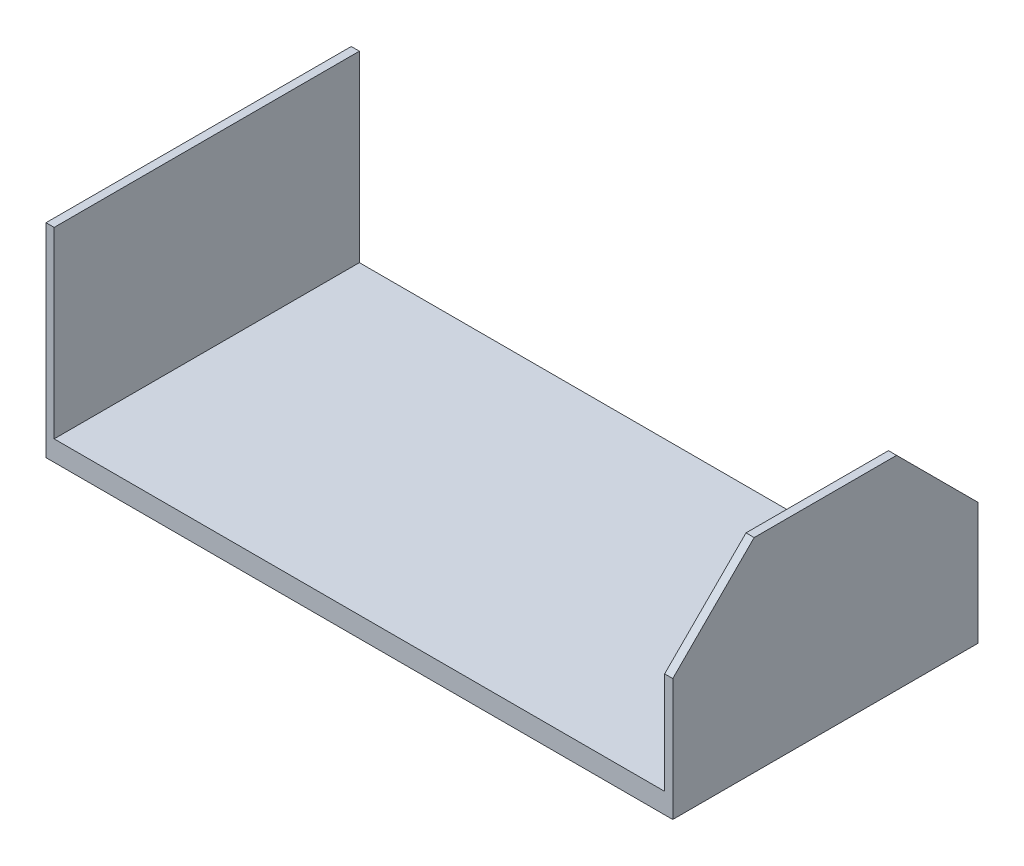
from build123d import *

# Parameters (mm, degrees)
SKETCH1_W           = 150
SKETCH1_H           = 75
BOSS_EXTRUDE1_DEPTH = 5
SKETCH2_W           = 75
SKETCH2_H           = 50
BOSS_EXTRUDE2_DEPTH = 2
CHAMFER1_SIZE       = 20


with BuildPart() as part:
    # Sketch1 → Boss-Extrude1 (new body)
    with BuildSketch(Plane(origin=(0, 0, 0), x_dir=(1, 0, 0), z_dir=(0, 1, 0))):
        Rectangle(SKETCH1_W, SKETCH1_H)
    extrude(amount=BOSS_EXTRUDE1_DEPTH)

    # Sketch2 → Boss-Extrude2 (add)
    with BuildSketch(Plane.ZY.offset(75)):
        with Locations((0, 25)):
            Rectangle(SKETCH2_W, SKETCH2_H)
    boss_extrude2 = extrude(amount=BOSS_EXTRUDE2_DEPTH)

    # Mirror1: Boss-Extrude2 across plane
    add(boss_extrude2.mirror(Plane(origin=(0, 0, 0), x_dir=(0, 0, 1), z_dir=(1, 0, 0))))

    # Chamfer1
    chamfer1_edges = [part.edges().sort_by_distance(p)[0] for p in [
        (76, 50, -37.5),
        (76, 50, 37.5),
    ]]
    chamfer(chamfer1_edges, length=CHAMFER1_SIZE)


solid = part.part
